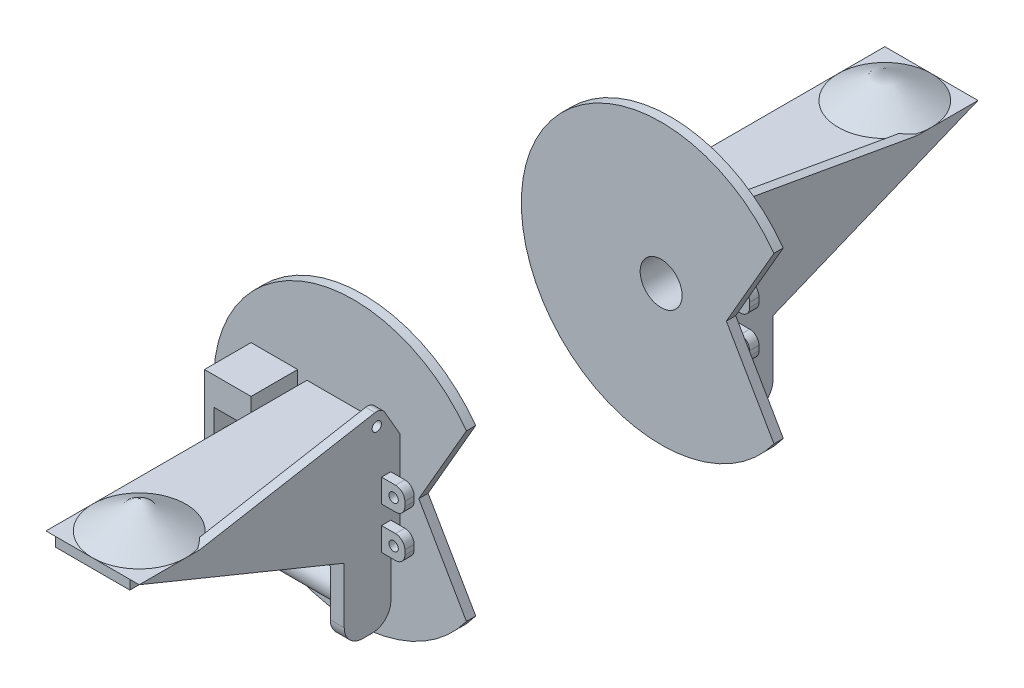
from build123d import *

# Parameters (mm, degrees)
SZKIC1_W                     = 100
SZKIC1_H                     = 100
DODANIE_WYCI_GNI_CIE1_DEPTH  = 40
SZKIC3_R                     = 22.5
WYTNIJ_WYCI_GNI_CIE1_DEPTH   = 41
SZKIC4_W                     = 100
SZKIC4_H                     = 10
DODANIE_WYCI_GNI_CIE2_DEPTH  = 30
DODANIE_WYCI_GNI_CIE3_DEPTH  = 10
DODANIE_WYCI_GNI_CIE4_DEPTH  = 10
DODANIE_WYCI_GNI_CIE5_DEPTH  = 10
SZKIC11_W                    = 15
SZKIC11_H                    = 50
DODANIE_WYCI_GNI_CIE6_DEPTH  = 70
SZKIC12_R                    = 15
DODANIE_WYCI_GNI_CIE7_DEPTH  = 125
SZKIC13_R                    = 15
DODANIE_WYCI_GNI_CIE8_DEPTH  = 30
DODANIE_WYCI_GNI_CIE9_DEPTH  = 10
ZAOKR_GLENIE1_R              = 20
SZKIC15_W                    = 50
SZKIC15_H                    = 185
DODANIE_WYCI_GNI_CIE10_DEPTH = 10
DODANIE_WYCI_GNI_CIE11_REACH = 52
SZKIC17_W                    = 50
SZKIC17_H                    = 30
SZKIC18_W                    = 100
SZKIC18_H                    = 100
DODANIE_WYCI_GNI_CIE12_DEPTH = 10
DODANIE_WYCI_GNI_CIE13_DEPTH = 10
WYTNIJ_WYCI_GNI_CIE2_REACH   = 202
SZKIC20_R                    = 5
SZKIC21_W                    = 10
SZKIC21_H                    = 25
DODANIE_WYCI_GNI_CIE14_DEPTH = 25
ZAOKR_GLENIE2_R              = 10
WYTNIJ_WYCI_GNI_CIE3_REACH   = 32
SZKIC22_R                    = 5


with BuildPart() as part:
    # Szkic1 → Dodanie-wyciągnięcie1 (new body)
    with BuildSketch(Plane.XY):
        Rectangle(SZKIC1_W, SZKIC1_H)
    extrude(amount=DODANIE_WYCI_GNI_CIE1_DEPTH)

    # Szkic3 → Wytnij-wyciągnięcie1 (cut, through all)
    with BuildSketch(Plane.XY.offset(40)):
        Circle(SZKIC3_R)
    extrude(amount=-WYTNIJ_WYCI_GNI_CIE1_DEPTH, mode=Mode.SUBTRACT)

    # Szkic4 → Dodanie-wyciągnięcie2 (add)
    with BuildSketch(Plane(origin=(0, 0, 0), x_dir=(-1, 0, 0), z_dir=(0, 0, -1))):
        with Locations((0, -45)):
            Rectangle(SZKIC4_W, SZKIC4_H)
    extrude(amount=DODANIE_WYCI_GNI_CIE2_DEPTH)

    # Szkic5 → Dodanie-wyciągnięcie3 (add)
    with BuildSketch(Plane.ZY.offset(50)):
        Polygon((-30, -40), (-250, 50), (0, 50), (0, -40), align=None)
    extrude(amount=-DODANIE_WYCI_GNI_CIE3_DEPTH)

    # Szkic6 → Dodanie-wyciągnięcie4 (add)
    with BuildSketch(Plane(origin=(50, 0, 0), x_dir=(0, 0, -1), z_dir=(1, 0, 0))):
        Polygon((30, -40), (250, 50), (0, 50), (0, -40), align=None)
    extrude(amount=-DODANIE_WYCI_GNI_CIE4_DEPTH)

    # Szkic7 → Dodanie-wyciągnięcie5 (add)
    with BuildSketch(Plane(origin=(0, 50, 0), x_dir=(1, 0, 0), z_dir=(0, 1, 0))):
        Polygon((40, 250), (-40, 250), (-40, 30), (-40, 0), (40, 0), align=None)
    extrude(amount=-DODANIE_WYCI_GNI_CIE5_DEPTH)

    # Szkic10 → Obrót1 (revolve)
    with BuildSketch(Plane(origin=(0, 0, -200), x_dir=(-1, 0, 0), z_dir=(0, 0, -1))):
        Polygon((0, 50), (0, 80), (-50, 50), align=None)
    revolve(axis=Axis((0, 50, -200), (0, 1, 0)))

    # Szkic11 → Dodanie-wyciągnięcie6 (add)
    with BuildSketch(Plane.XZ.offset(50)):
        with Locations((42.5, -5)):
            Rectangle(SZKIC11_W, SZKIC11_H)
    extrude(amount=DODANIE_WYCI_GNI_CIE6_DEPTH)

    # Szkic12 → Dodanie-wyciągnięcie7 (add)
    with BuildSketch(Plane.ZY.offset(-35)):
        with Locations((-5, -85)):
            Circle(SZKIC12_R)
    extrude(amount=DODANIE_WYCI_GNI_CIE7_DEPTH)

    # Szkic13 → Dodanie-wyciągnięcie8 (add)
    with BuildSketch(Plane.ZY.offset(50)):
        with Locations((-40, 0)):
            Circle(SZKIC13_R)
    extrude(amount=DODANIE_WYCI_GNI_CIE8_DEPTH)

    # Szkic14 → Dodanie-wyciągnięcie9 (add)
    with BuildSketch(Plane.ZY.offset(60)):
        Polygon((-69.010894517, 20.037063975), (-26.999775325, 36.163621704), (26.755417107, -103.87344227), (-15.255702085, -120), align=None)
    extrude(amount=DODANIE_WYCI_GNI_CIE9_DEPTH)

    # Zaokrąglenie1
    zaokr_glenie1_edges = [part.edges().sort_by_distance(p)[0] for p in [
        (-65, 20.037063975, -69.010894517),
        (-65, -120, -15.255702085),
        (-65, -103.87344227, 26.755417107),
        (-65, 36.163621704, -26.999775325),
        (42.5, -120, 20),
        (42.5, -120, -30),
    ]]
    fillet(zaokr_glenie1_edges, radius=ZAOKR_GLENIE1_R)

    # Szkic15 → Dodanie-wyciągnięcie10 (add)
    with BuildSketch(Plane.ZY.offset(90)):
        with Locations((-5, -27.5)):
            Rectangle(SZKIC15_W, SZKIC15_H)
    extrude(amount=DODANIE_WYCI_GNI_CIE10_DEPTH)

    # Szkic17 → Dodanie-wyciągnięcie11 (add, up to next)
    with BuildSketch(Plane.ZY.offset(50), mode=Mode.PRIVATE) as dodanie_wyci_gni_cie11_sk1:
        with Locations((-5, 50)):
            Rectangle(SZKIC17_W, SZKIC17_H)
    dodanie_wyci_gni_cie11_tool1 = extrude(dodanie_wyci_gni_cie11_sk1.sketch, amount=DODANIE_WYCI_GNI_CIE11_REACH, mode=Mode.PRIVATE) - part.part
    add(dodanie_wyci_gni_cie11_tool1.solids().sort_by_distance((-50, 50, -5))[0])

    # Szkic18 → Dodanie-wyciągnięcie12 (add)
    with BuildSketch(Plane.XY.offset(40)):
        with BuildLine():
            Line((70, 0), (121.10211367, 88.511457251))
            ThreePointArc((121.10211367, 88.511457251), (-150, 0), (121.10211367, -88.511457251))
            Line((121.10211367, -88.511457251), (70, 0))
        make_face()
        Rectangle(SZKIC18_W, SZKIC18_H, mode=Mode.SUBTRACT)
    extrude(amount=-DODANIE_WYCI_GNI_CIE12_DEPTH)

    # Szkic19 → Dodanie-wyciągnięcie13 (add)
    with BuildSketch(Plane(origin=(50, 0, 0), x_dir=(0, 0, -1), z_dir=(1, 0, 0))):
        Polygon((-30, 50), (-9.958560776, 84.617058134), (185, 50), align=None)
    extrude(amount=-DODANIE_WYCI_GNI_CIE13_DEPTH)

    # Szkic20 → Wytnij-wyciągnięcie2 (cut, up to next)
    with BuildSketch(Plane(origin=(50, 0, 0), x_dir=(0, 0, -1), z_dir=(1, 0, 0)), mode=Mode.PRIVATE) as wytnij_wyci_gni_cie2_sk1:
        with Locations((-4.958560776, 69.617058134)):
            Circle(SZKIC20_R)
    wytnij_wyci_gni_cie2_tool1 = extrude(wytnij_wyci_gni_cie2_sk1.sketch, amount=-WYTNIJ_WYCI_GNI_CIE2_REACH, mode=Mode.PRIVATE) & part.part
    add(wytnij_wyci_gni_cie2_tool1.solids().sort_by_distance((50, 69.617058, 4.958561))[0], mode=Mode.SUBTRACT)

    # Szkic21 → Dodanie-wyciągnięcie14 (add)
    with BuildSketch(Plane(origin=(50, 0, 0), x_dir=(0, 0, -1), z_dir=(1, 0, 0))):
        with Locations((-15, 7.5)):
            Rectangle(SZKIC21_W, SZKIC21_H)
        with Locations((-15, -37.5)):
            Rectangle(SZKIC21_W, SZKIC21_H)
    extrude(amount=DODANIE_WYCI_GNI_CIE14_DEPTH)

    # Zaokrąglenie2
    zaokr_glenie2_edges = [part.edges().sort_by_distance(p)[0] for p in [
        (45, 84.617058134, 9.958560776),
        (75, 20, 15),
        (75, -5, 15),
        (75, -25, 15),
        (75, -50, 15),
    ]]
    fillet(zaokr_glenie2_edges, radius=ZAOKR_GLENIE2_R)

    # Szkic22 → Wytnij-wyciągnięcie3 (cut, up to next)
    with BuildSketch(Plane(origin=(0, 0, 10), x_dir=(-1, 0, 0), z_dir=(0, 0, -1)), mode=Mode.PRIVATE) as wytnij_wyci_gni_cie3_sk1:
        with Locations((-63, 7.5)):
            Circle(SZKIC22_R)
    wytnij_wyci_gni_cie3_tool1 = extrude(wytnij_wyci_gni_cie3_sk1.sketch, amount=-WYTNIJ_WYCI_GNI_CIE3_REACH, mode=Mode.PRIVATE) & part.part
    add(wytnij_wyci_gni_cie3_tool1.solids().sort_by_distance((63, 7.5, 10))[0], mode=Mode.SUBTRACT)
    # Szkic22 → Wytnij-wyciągnięcie3 (cut, up to next)
    with BuildSketch(Plane(origin=(0, 0, 10), x_dir=(-1, 0, 0), z_dir=(0, 0, -1)), mode=Mode.PRIVATE) as wytnij_wyci_gni_cie3_sk2:
        with Locations((-63, -37.5)):
            Circle(SZKIC22_R)
    wytnij_wyci_gni_cie3_tool2 = extrude(wytnij_wyci_gni_cie3_sk2.sketch, amount=-WYTNIJ_WYCI_GNI_CIE3_REACH, mode=Mode.PRIVATE) & part.part
    add(wytnij_wyci_gni_cie3_tool2.solids().sort_by_distance((63, -37.5, 10))[0], mode=Mode.SUBTRACT)


with BuildPart() as body_2:
    # Lustro2: mirrored copy
    add(part.part.mirror(Plane.XY.offset(200)))


solid = Compound([part.part, body_2.part])
